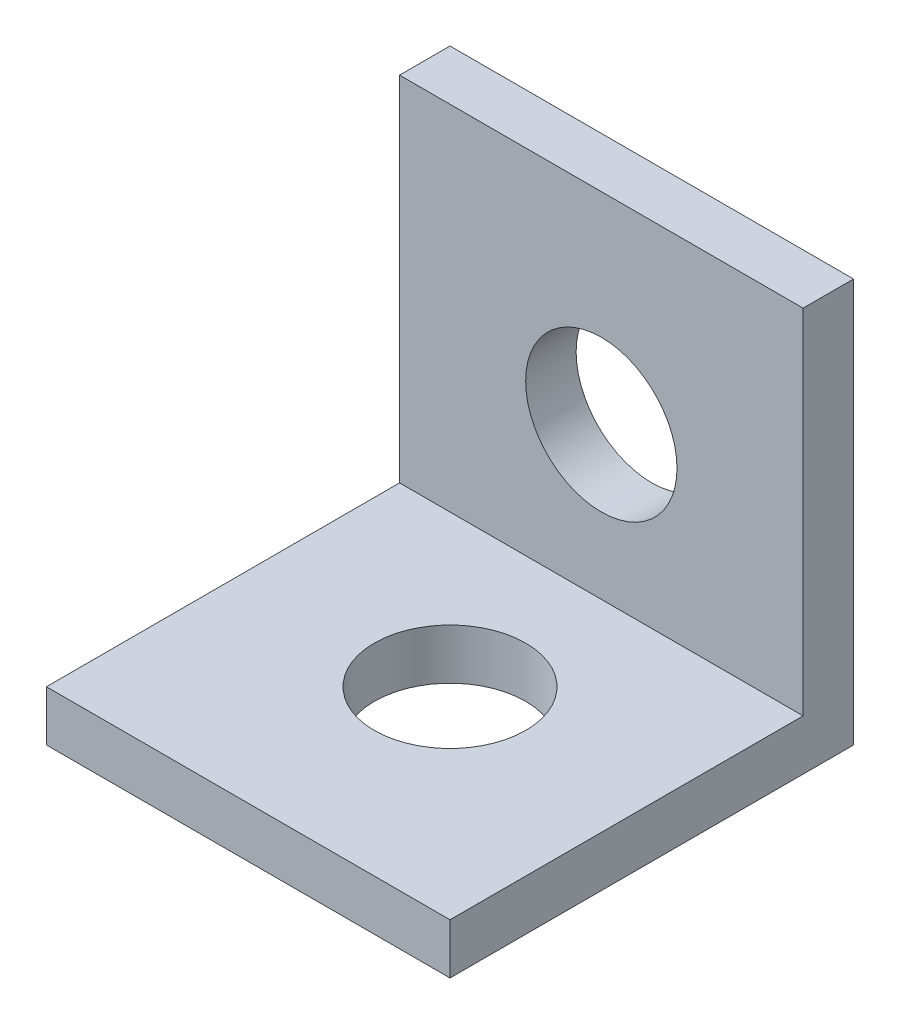
from build123d import *

# Parameters (mm, degrees)
BOSS_EXTRUDE1_DEPTH = 25.4
SKETCH2_R           = 4.7625
CUT_EXTRUDE1_DEPTH  = 25.4
SKETCH3_R           = 4.7625
CUT_EXTRUDE2_DEPTH  = 4.175


with BuildPart() as part:
    # Sketch1 → Boss-Extrude1 (new body)
    with BuildSketch(Plane(origin=(0, 0, 0), x_dir=(0, 0, -1), z_dir=(1, 0, 0))):
        Polygon((0, 0), (-25.4, 0), (-25.4, 3.175), (-3.175, 3.175), (-3.175, 25.4), (0, 25.4), align=None)
    extrude(amount=BOSS_EXTRUDE1_DEPTH)

    # Sketch2 → Cut-Extrude1 (cut)
    with BuildSketch(Plane(origin=(0, 3.175, 0), x_dir=(1, 0, 0), z_dir=(0, 1, 0))):
        with Locations((12.7, -12.7)):
            Circle(SKETCH2_R)
    extrude(amount=-CUT_EXTRUDE1_DEPTH, mode=Mode.SUBTRACT)

    # Sketch3 → Cut-Extrude2 (cut, through all)
    with BuildSketch(Plane.XY.offset(3.175)):
        with Locations((12.7, 12.7)):
            Circle(SKETCH3_R)
    extrude(amount=-CUT_EXTRUDE2_DEPTH, mode=Mode.SUBTRACT)


solid = part.part
